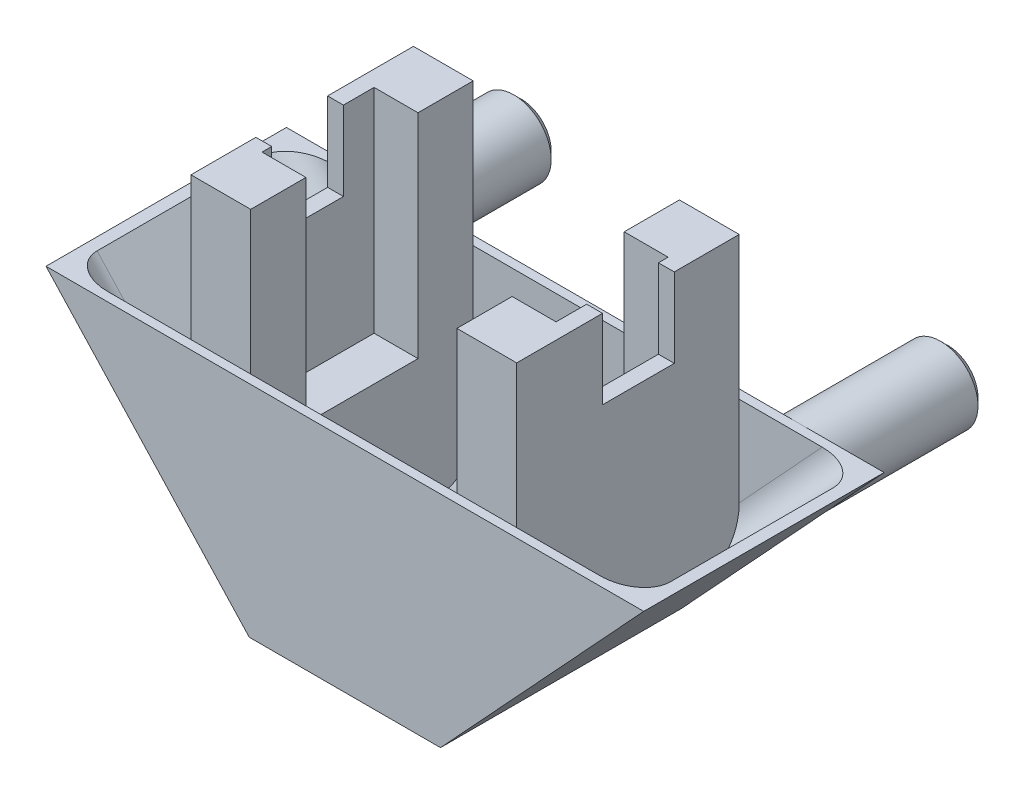
from build123d import *

# Parameters (mm, degrees)
AUFSATZ_LINEAR_AUSTRAGEN1_DEPTH  = 16.09
WANDUNG2_T                       = -0.6
VERRUNDUNG1_R                    = 2
VERRUNDUNG2_R                    = 2
SKIZZE7_R                        = 2.5
AUFSATZ_LINEAR_AUSTRAGEN4_DEPTH  = 10
FASE3_SIZE                       = 0.5
AUFSATZ_LINEAR_AUSTRAGEN8_DEPTH  = 7.85
SKIZZE14_W                       = 3.695
SKIZZE14_H                       = 14.25
AUFSATZ_LINEAR_AUSTRAGEN9_DEPTH  = 2.94
SKIZZE15_W                       = 14.89
SKIZZE15_H                       = 14.52
AUFSATZ_LINEAR_AUSTRAGEN10_DEPTH = 1.06
SCHNITT_LINEAR_AUSTRAGEN1_REACH  = 12.16
SKIZZE16_W                       = 4.8
SKIZZE16_H                       = 5.3
SKIZZE17_W                       = 14.89
SKIZZE17_H                       = 14.52
AUFSATZ_LINEAR_AUSTRAGEN11_DEPTH = 1.06
SCHNITT_LINEAR_AUSTRAGEN2_REACH  = 12.16
SKIZZE18_W                       = 4.8
SKIZZE18_H                       = 5.3


with BuildPart() as part:
    # Skizze4 → Aufsatz-Linear austragen1 (new body)
    with BuildSketch(Plane.XY):
        Polygon((-6.4, 0), (-20, 14.7), (20, 14.7), (6.4, 0), align=None)
    extrude(amount=AUFSATZ_LINEAR_AUSTRAGEN1_DEPTH)

    # Wandung2
    wandung2_openings = [part.faces().sort_by_distance(p)[0] for p in [
        (0, 14.7, 8.045),
        (0, 0, 8.045),
    ]]
    offset(amount=WANDUNG2_T, openings=wandung2_openings, kind=Kind.INTERSECTION)

    # Verrundung1
    verrundung1_edges = [part.edges().sort_by_distance(p)[0] for p in [
        (12.382602743, 7.35, 15.49),
        (-12.382602743, 7.35, 15.49),
    ]]
    fillet(verrundung1_edges, radius=VERRUNDUNG1_R)

    # Verrundung2
    verrundung2_edges = [part.edges().sort_by_distance(p)[0] for p in [
        (12.382602743, 7.35, 0.6),
        (-12.382602743, 7.35, 0.6),
    ]]
    fillet(verrundung2_edges, radius=VERRUNDUNG2_R)

    # Skizze7 → Aufsatz-Linear austragen4 (add)
    with BuildSketch(Plane(origin=(0, 0, 0), x_dir=(-1, 0, 0), z_dir=(0, 0, -1))):
        with Locations((-14.281252926, 12.2)):
            Circle(SKIZZE7_R)
        with Locations((14.281252926, 12.2)):
            Circle(SKIZZE7_R)
    extrude(amount=AUFSATZ_LINEAR_AUSTRAGEN4_DEPTH)

    # Fase3
    fase3_edges = [part.edges().sort_by_distance(p)[0] for p in [
        (16.781252926, 12.2, -10),
        (-11.781252926, 12.2, -10),
    ]]
    chamfer(fase3_edges, length=FASE3_SIZE)

    # Skizze12 → Aufsatz-Linear austragen8 (add, symmetric)
    with BuildSketch(Plane.XY.offset(8.045)):
        Polygon((6.9, 0.540441176), (6.9, 10), (10.9, 10), (10.9, 4.863970588), align=None)
    aufsatz_linear_austragen8 = extrude(amount=AUFSATZ_LINEAR_AUSTRAGEN8_DEPTH, both=True)

    # Spiegeln6: Aufsatz-Linear austragen8 across plane
    add(aufsatz_linear_austragen8.mirror(Plane(origin=(0, 0, 0), x_dir=(0, 0, 1), z_dir=(1, 0, 0))))

    # Skizze14 → Aufsatz-Linear austragen9 (add)
    with BuildSketch(Plane.ZY.offset(-9.84)):
        with Locations((2.4475, 17.125)):
            Rectangle(SKIZZE14_W, SKIZZE14_H)
        with Locations((13.6425, 17.125)):
            Rectangle(SKIZZE14_W, SKIZZE14_H)
    aufsatz_linear_austragen9 = extrude(amount=AUFSATZ_LINEAR_AUSTRAGEN9_DEPTH)

    # Skizze15 → Aufsatz-Linear austragen10 (add)
    with BuildSketch(Plane(origin=(9.84, 0, 0), x_dir=(0, 0, -1), z_dir=(1, 0, 0))):
        with Locations((-8.045, 16.99)):
            Rectangle(SKIZZE15_W, SKIZZE15_H)
    extrude(amount=AUFSATZ_LINEAR_AUSTRAGEN10_DEPTH)

    # Skizze16 → Schnitt-Linear austragen1 (cut, up to next)
    with BuildSketch(Plane.ZY.offset(-9.84), mode=Mode.PRIVATE) as schnitt_linear_austragen1_sk1:
        with Locations((7.345, 21.6)):
            Rectangle(SKIZZE16_W, SKIZZE16_H)
    schnitt_linear_austragen1_tool1 = extrude(schnitt_linear_austragen1_sk1.sketch, amount=-SCHNITT_LINEAR_AUSTRAGEN1_REACH, mode=Mode.PRIVATE) & part.part
    add(schnitt_linear_austragen1_tool1.solids().sort_by_distance((9.84, 21.6, 7.345))[0], mode=Mode.SUBTRACT)

    # Spiegeln9: Aufsatz-Linear austragen9 across plane
    add(aufsatz_linear_austragen9.mirror(Plane(origin=(0, 0, 0), x_dir=(0, 0, 1), z_dir=(1, 0, 0))))

    # Skizze17 → Aufsatz-Linear austragen11 (add)
    with BuildSketch(Plane.ZY.offset(9.84)):
        with Locations((8.045, 16.99)):
            Rectangle(SKIZZE17_W, SKIZZE17_H)
    extrude(amount=AUFSATZ_LINEAR_AUSTRAGEN11_DEPTH)

    # Skizze18 → Schnitt-Linear austragen2 (cut, up to next)
    with BuildSketch(Plane(origin=(-9.84, 0, 0), x_dir=(0, 0, -1), z_dir=(1, 0, 0)), mode=Mode.PRIVATE) as schnitt_linear_austragen2_sk1:
        with Locations((-8.745, 21.6)):
            Rectangle(SKIZZE18_W, SKIZZE18_H)
    schnitt_linear_austragen2_tool1 = extrude(schnitt_linear_austragen2_sk1.sketch, amount=-SCHNITT_LINEAR_AUSTRAGEN2_REACH, mode=Mode.PRIVATE) & part.part
    add(schnitt_linear_austragen2_tool1.solids().sort_by_distance((-9.84, 21.6, 8.745))[0], mode=Mode.SUBTRACT)


solid = part.part
